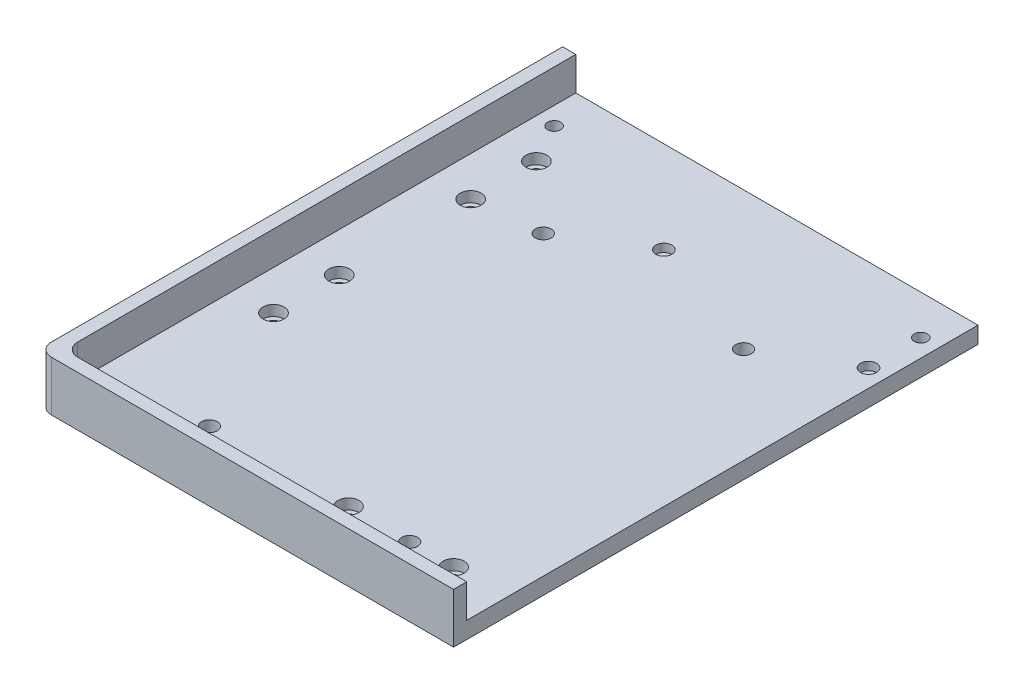
from build123d import *

# Parameters (mm, degrees)
SKETCH1_W                      = 158
SKETCH1_H                      = 199.5
BOSS_EXTRUDE1_DEPTH            = 6.35
BOSS_EXTRUDE2_DEPTH            = 12.7
CBORE_FOR_M4_SHCS1_D           = 4.5
CBORE_FOR_M4_SHCS1_DEPTH       = 6.35
CBORE_FOR_M4_SHCS1_CBORE_D     = 8
CBORE_FOR_M4_SHCS1_CBORE_DEPTH = 4
FILLET2_R                      = 5
SKETCH8_R                      = 3
ENCLOSURE_MOUNT_DEPTH          = 7.35
SKETCH9_R                      = 2.5
FUSE_MOUNT_DEPTH               = 7.35
SKETCH10_R                     = 3.05
MAGNETS_DEPTH                  = 3.1


with BuildPart() as part:
    # Sketch1 → Boss-Extrude1 (new body)
    with BuildSketch(Plane(origin=(0, 0, 0), x_dir=(1, 0, 0), z_dir=(0, 1, 0))):
        with Locations((79, -99.75)):
            Rectangle(SKETCH1_W, SKETCH1_H)
    extrude(amount=BOSS_EXTRUDE1_DEPTH)

    # Sketch3 → Boss-Extrude2 (add)
    with BuildSketch(Plane(origin=(0, 6.35, 0), x_dir=(1, 0, 0), z_dir=(0, 1, 0))):
        Polygon((0, 0), (0, -199.5), (158, -199.5), (158, -194.5), (5, -194.5), (5, 0), align=None)
    extrude(amount=BOSS_EXTRUDE2_DEPTH)

    # CBORE for M4 SHCS1
    with Locations(Plane(origin=(0, 6.35, 0), x_dir=(1, 0, 0), z_dir=(0, 1, 0))):
        with Locations((20, -55), (98, -179.5), (138, -179.5), (20, -130), (20, -105), (20, -30)):
            CounterBoreHole(CBORE_FOR_M4_SHCS1_D / 2, CBORE_FOR_M4_SHCS1_CBORE_D / 2, CBORE_FOR_M4_SHCS1_CBORE_DEPTH, depth=CBORE_FOR_M4_SHCS1_DEPTH)

    # Fillet2
    fillet2_edges = [part.edges().sort_by_distance(p)[0] for p in [
        (5, 12.7, 194.5),
        (0, 9.525, 199.5),
    ]]
    fillet(fillet2_edges, radius=FILLET2_R)

    # Sketch8 → Enclosure Mount (cut, through all)
    with BuildSketch(Plane(origin=(0, 6.35, 0), x_dir=(1, 0, 0), z_dir=(0, 1, 0))):
        with Locations((45.1, -52.5)):
            Circle(SKETCH8_R)
        with Locations((121.3, -52.5)):
            Circle(SKETCH8_R)
        with Locations((121.3, -179.5)):
            Circle(SKETCH8_R)
        with Locations((45.1, -179.5)):
            Circle(SKETCH8_R)
    extrude(amount=-ENCLOSURE_MOUNT_DEPTH, mode=Mode.SUBTRACT)

    # Sketch9 → Fuse Mount (cut, through all)
    with BuildSketch(Plane(origin=(0, 6.35, 0), x_dir=(1, 0, 0), z_dir=(0, 1, 0))):
        with Locations((11.75, -15)):
            Circle(SKETCH9_R)
        with Locations((151.25, -15)):
            Circle(SKETCH9_R)
    extrude(amount=-FUSE_MOUNT_DEPTH, mode=Mode.SUBTRACT)

    # Sketch10 → Magnets (cut)
    with BuildSketch(Plane(origin=(0, 6.35, 0), x_dir=(1, 0, 0), z_dir=(0, 1, 0))):
        with Locations((151.25, -34.9)):
            Circle(SKETCH10_R)
        with Locations((73.375, -34.9)):
            Circle(SKETCH10_R)
    extrude(amount=-MAGNETS_DEPTH, mode=Mode.SUBTRACT)


solid = part.part
